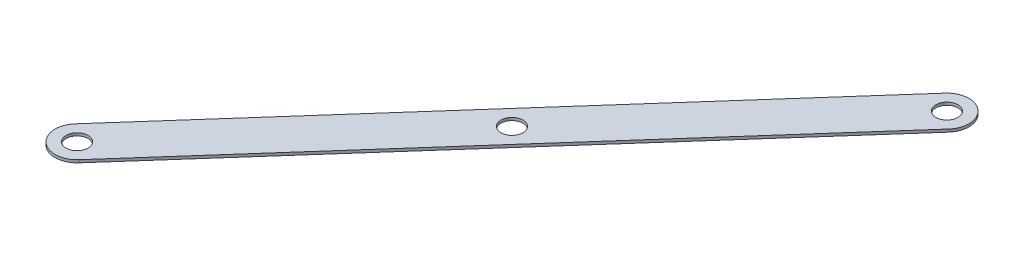
from build123d import *

# Parameters (mm, degrees)
SKETCH1_R           = 6.35
BOSS_EXTRUDE1_DEPTH = 1.5875


with BuildPart() as part:
    # Sketch1 → Boss-Extrude1 (new body)
    with BuildSketch(Plane(origin=(0, 0, 0), x_dir=(1, 0, 0), z_dir=(0, 1, 0))):
        with BuildLine():
            Line((-9.511548238, 8.415488704), (226.122135464, 274.738839361))
            ThreePointArc((226.122135464, 274.738839361), (244.049172405, 275.834898895), (245.145231939, 257.907861953))
            Line((245.145231939, 257.907861953), (9.511548238, -8.415488704))
            ThreePointArc((9.511548238, -8.415488704), (-8.415488704, -9.511548238), (-9.511548238, 8.415488704))
        make_face()
        with Locations((117.816841851, 133.161675329)):
            Circle(SKETCH1_R, mode=Mode.SUBTRACT)
        with Locations((235.633683702, 266.323350657)):
            Circle(SKETCH1_R, mode=Mode.SUBTRACT)
        Circle(SKETCH1_R, mode=Mode.SUBTRACT)
    extrude(amount=BOSS_EXTRUDE1_DEPTH)


solid = part.part
